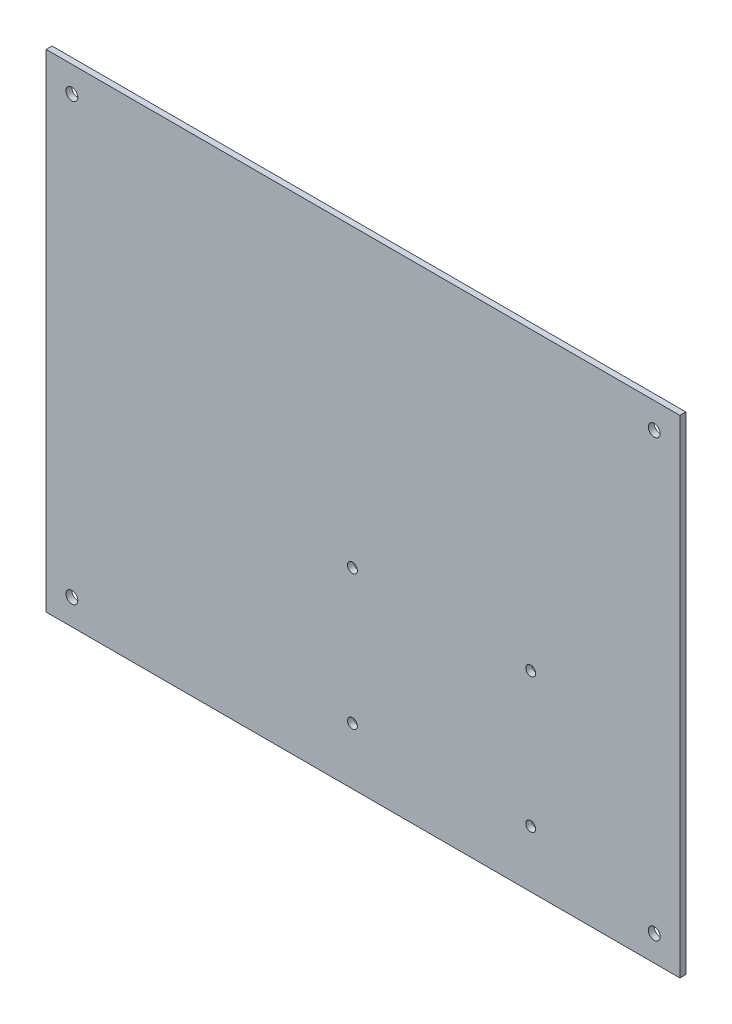
from build123d import *

# Parameters (mm, degrees)
SKETCH_1_W               = 1600
SKETCH_1_H               = 1230
SKETCH_1_R               = 15
EXTRUDE_1_DEPTH          = 3
SCALE_1_SCALE_X          = 0.1
SCALE_1_SCALE_Y          = 0.1
SCALE_1_SCALE_Z          = 0.5
SKETCH_2_R               = 1.25
CUT_EXTRUDE_4_DEPTH      = 1.0000001
CUT_EXTRUDE_4_DEPTH_BACK = 2.5000001


with BuildPart() as part:
    # 草图1 → 凸台-拉伸1 (new body)
    with BuildSketch(Plane.XY):
        with Locations((1152.60835314, -1687.80288964)):
            Rectangle(SKETCH_1_W, SKETCH_1_H)
        with Locations((417.60835314, -1137.80288964)):
            Circle(SKETCH_1_R, mode=Mode.SUBTRACT)
        with Locations((1887.60835314, -1137.80288964)):
            Circle(SKETCH_1_R, mode=Mode.SUBTRACT)
        with Locations((1887.60835314, -2237.80288964)):
            Circle(SKETCH_1_R, mode=Mode.SUBTRACT)
        with Locations((417.60835314, -2237.80288964)):
            Circle(SKETCH_1_R, mode=Mode.SUBTRACT)
    extrude(amount=EXTRUDE_1_DEPTH)


with BuildPart() as part_1:
    # 缩放比例1: scaled about (1152.60835314, -1687.80288964, 1.5)
    add(part.part.scale((SCALE_1_SCALE_X, SCALE_1_SCALE_Y, SCALE_1_SCALE_Z), about=(1152.60835314, -1687.80288964, 1.5)))

    # 草图2 → 切除-拉伸4 (cut, two sides)
    with BuildSketch(Plane.XY.offset(2.25)) as cut_extrude_4_sk:
        with Locations((1149.93385314, -1700.96117964)):
            Circle(SKETCH_2_R)
        with Locations((1194.93385314, -1700.96117964)):
            Circle(SKETCH_2_R)
        with Locations((1149.93385314, -1734.96117964)):
            Circle(SKETCH_2_R)
        with Locations((1194.93385314, -1734.96117964)):
            Circle(SKETCH_2_R)
    extrude(amount=CUT_EXTRUDE_4_DEPTH, mode=Mode.SUBTRACT)
    extrude(cut_extrude_4_sk.sketch, amount=-CUT_EXTRUDE_4_DEPTH_BACK, mode=Mode.SUBTRACT)


solid = part_1.part
